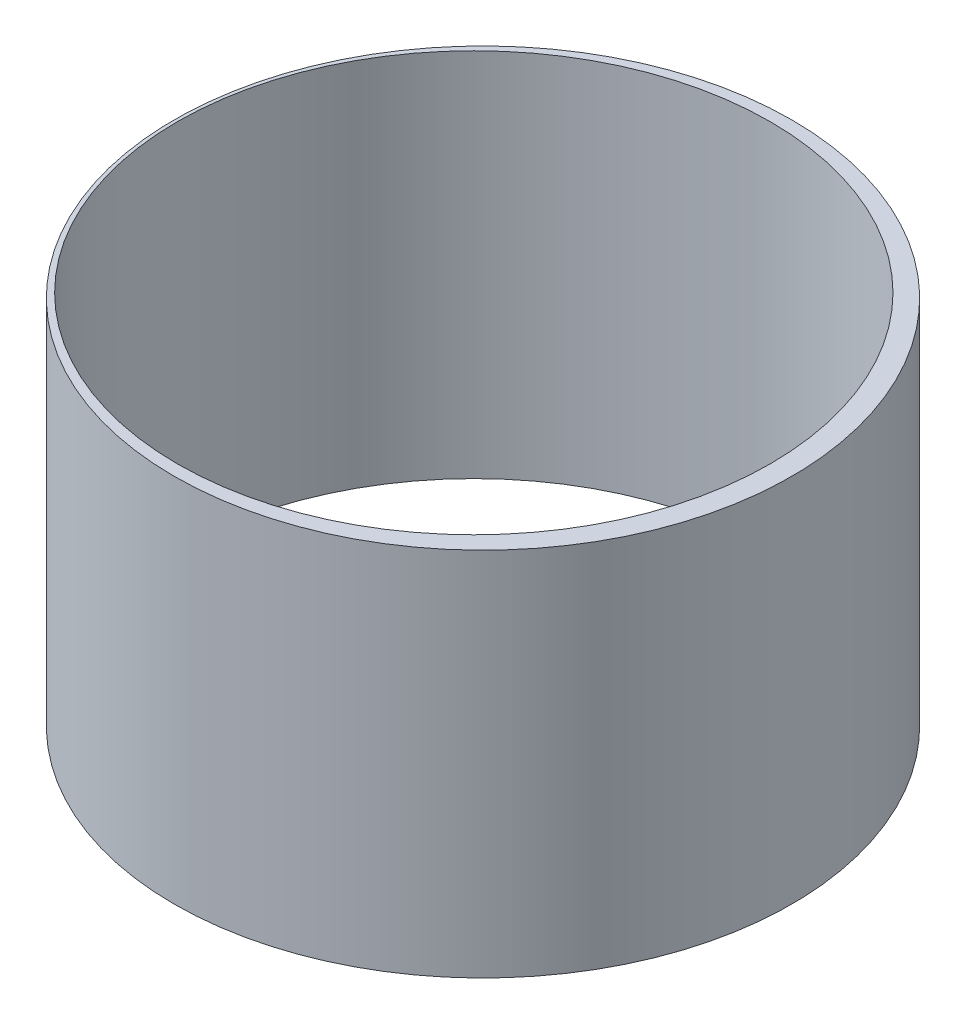
from build123d import *

# Parameters (mm, degrees)
SKETCH_1_R      = 25
SKETCH_1_R_2    = 24
EXTRUDE_1_DEPTH = 30


with BuildPart() as part:
    # 草图1 → 凸台-拉伸1 (new body)
    with BuildSketch(Plane(origin=(0, 0, 0), x_dir=(1, 0, 0), z_dir=(0, 1, 0))):
        Circle(SKETCH_1_R)
        with Locations((-0.744551615, 0)):
            Circle(SKETCH_1_R_2, mode=Mode.SUBTRACT)
    extrude(amount=EXTRUDE_1_DEPTH)


solid = part.part
